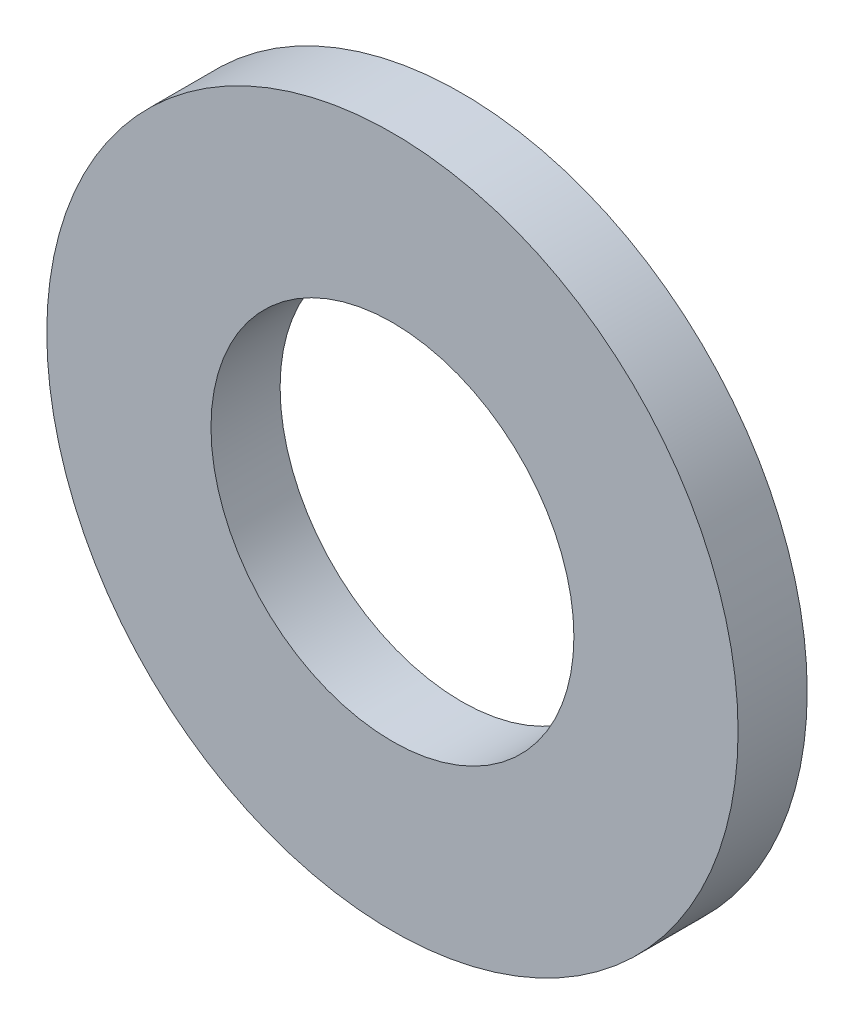
from build123d import *

# Parameters (mm, degrees)
SKETCH1_R          = 8
SKETCH1_R_2        = 4.2
BASE_EXTRUDE_DEPTH = 1.6


with BuildPart() as part:
    # Sketch1 → Base-Extrude (new body)
    with BuildSketch(Plane.XY):
        Circle(SKETCH1_R)
        Circle(SKETCH1_R_2, mode=Mode.SUBTRACT)
    extrude(amount=BASE_EXTRUDE_DEPTH)


solid = part.part
